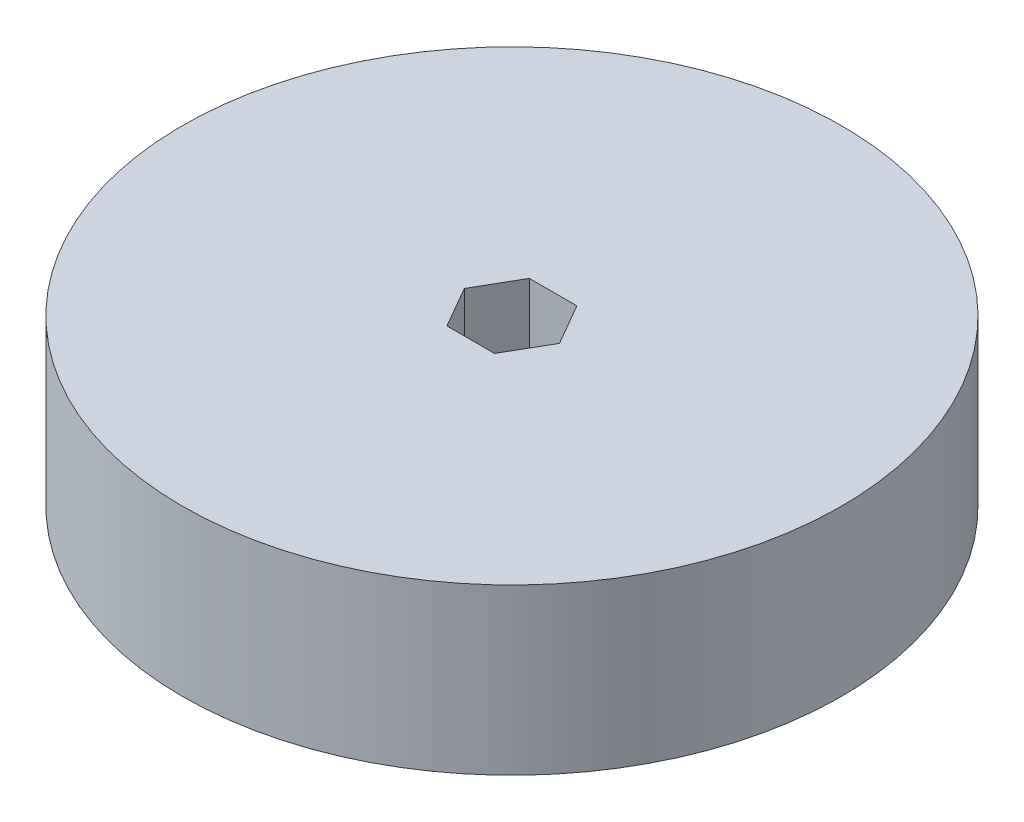
from build123d import *

# Parameters (mm, degrees)
SKETCH1_R           = 50.8
BOSS_EXTRUDE1_DEPTH = 25.4


with BuildPart() as part:
    # Sketch1 → Boss-Extrude1 (new body)
    with BuildSketch(Plane(origin=(0, 0, 0), x_dir=(1, 0, 0), z_dir=(0, 1, 0))):
        Circle(SKETCH1_R)
        Polygon((7.332348419, 0), (3.666174209, 6.35), (-3.666174209, 6.35), (-7.332348419, 0), (-3.666174209, -6.35), (3.666174209, -6.35), align=None, mode=Mode.SUBTRACT)
    extrude(amount=BOSS_EXTRUDE1_DEPTH)


solid = part.part
